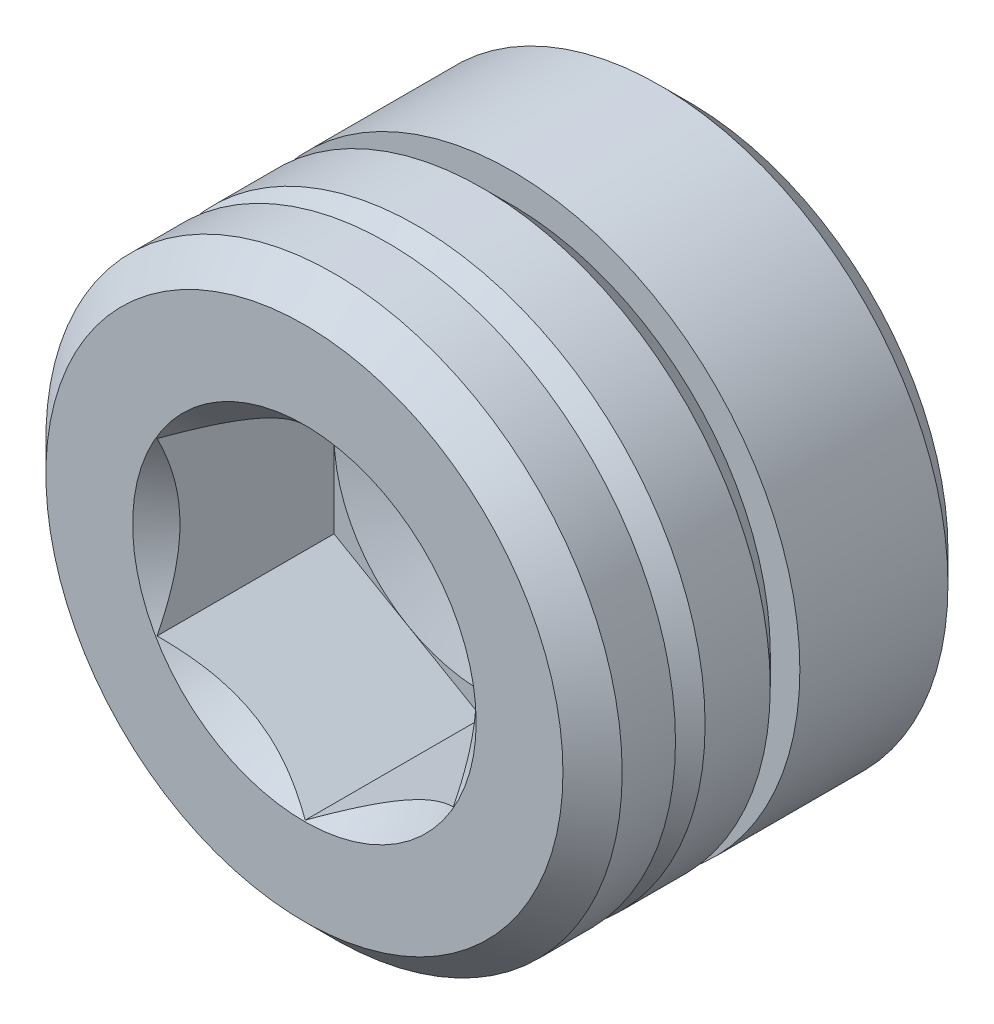
from build123d import *

# Parameters (mm, degrees)
CUT_EXTRUDE1_DEPTH = 3


with BuildPart() as part:
    # Sketch1 → Revolve1 (revolve)
    with BuildSketch(Plane(origin=(0, 0, 0), x_dir=(0, 0, -1), z_dir=(1, 0, 0))):
        Polygon((0, 0), (0, 4.365), (0.5, 4.865), (6, 4.865), (6.5, 4.365), (6.5, 0), align=None)
    revolve(axis=Axis((0, 0, -6.5), (0, 0, 1)))

    # Sketch2 → Cut-Revolve1 (revolve, cut)
    with BuildSketch(Plane(origin=(0, 0, 0), x_dir=(0, 0, -1), z_dir=(1, 0, 0))):
        Polygon((0, 4.865), (1.4, 4.865), (1.4, 4.365), (1.9, 4.865), (3, 4.865), (3.5, 4.365), (3.5, 4.865), (6.5, 4.865), (6.5, 9.865), (0, 9.865), align=None)
    revolve(axis=Axis((0, 0, -6.5), (0, 0, 1)), mode=Mode.SUBTRACT)

    # Sketch3 → Cut-Revolve2 (revolve, cut)
    with BuildSketch(Plane(origin=(0, 0, 0), x_dir=(0, 0, -1), z_dir=(1, 0, 0))):
        Polygon((0, 0), (0, 2.9), (0.4, 2.5), (3, 2.5), (3.69331136, 0), align=None)
    revolve(axis=Axis((0, 0, -3.69331136), (0, 0, 1)), mode=Mode.SUBTRACT)

    # Sketch4 → Cut-Extrude1 (cut)
    with BuildSketch(Plane.XY):
        Polygon((-2.5, -1.443375673), (0, -2.886751346), (2.5, -1.443375673), (2.5, 1.443375673), (0, 2.886751346), (-2.5, 1.443375673), align=None)
    extrude(amount=-CUT_EXTRUDE1_DEPTH, mode=Mode.SUBTRACT)


solid = part.part
